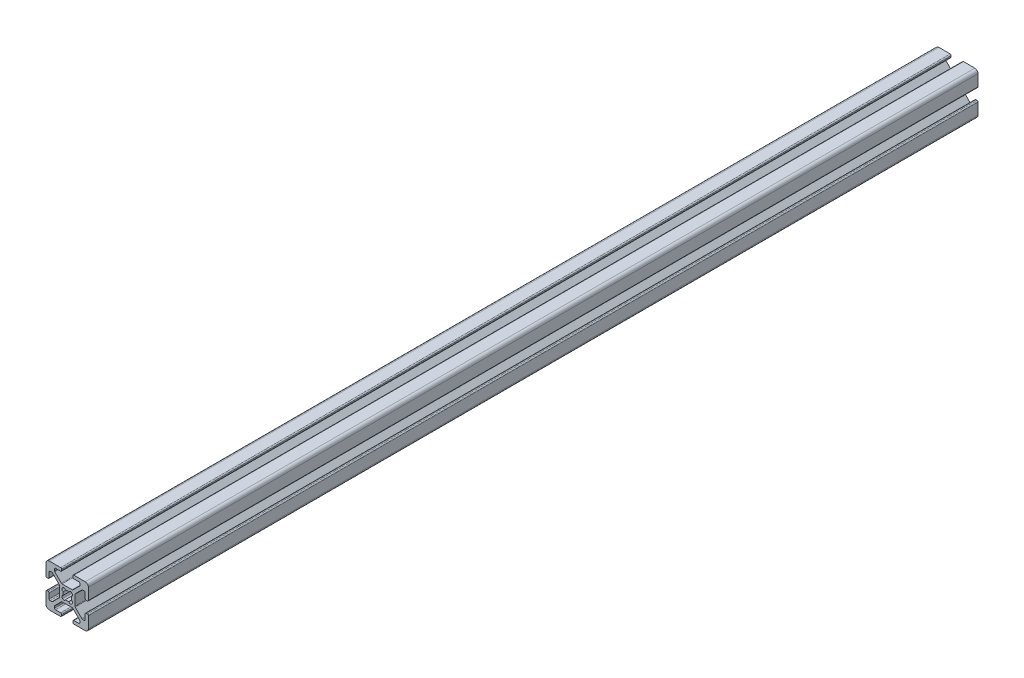
from build123d import *

# Parameters (mm, degrees)
EXTRUDE1_DEPTH = 420


with BuildPart() as part:
    # Sketch1 → Extrude1 (new body)
    with BuildSketch(Plane.XY):
        with BuildLine():
            Line((9.492, 2.63), (9.008, 2.63))
            ThreePointArc((9.008, 2.63), (8.648789755, 2.778789755), (8.5, 3.138))
            Line((8.5, 3.138), (8.5, 5.487))
            ThreePointArc((8.5, 5.487), (8.351210245, 5.846210245), (7.992, 5.995))
            Line((7.992, 5.995), (7.266080661, 5.995))
            ThreePointArc((7.266080661, 5.995), (7.071677478, 5.956330803), (6.906870417, 5.846210245))
            Line((6.906870417, 5.846210245), (3.803789755, 2.743129583))
            ThreePointArc((3.803789755, 2.743129583), (3.693669197, 2.578322522), (3.655, 2.383919339))
            Line((3.655, 2.383919339), (3.655, -2.383919339))
            ThreePointArc((3.655, -2.383919339), (3.693669197, -2.578322522), (3.803789755, -2.743129583))
            Line((3.803789755, -2.743129583), (6.906870417, -5.846210245))
            ThreePointArc((6.906870417, -5.846210245), (7.071677478, -5.956330803), (7.266080661, -5.995))
            Line((7.266080661, -5.995), (7.992, -5.995))
            ThreePointArc((7.992, -5.995), (8.351210245, -5.846210245), (8.5, -5.487))
            Line((8.5, -5.487), (8.5, -3.138))
            ThreePointArc((8.5, -3.138), (8.648789755, -2.778789755), (9.008, -2.63))
            Line((9.008, -2.63), (9.492, -2.63))
            ThreePointArc((9.492, -2.63), (9.851210245, -2.778789755), (10, -3.138))
            Line((10, -3.138), (10, -8.5))
            ThreePointArc((10, -8.5), (9.560660172, -9.560660172), (8.5, -10))
            Line((8.5, -10), (3.138, -10))
            ThreePointArc((3.138, -10), (2.778789755, -9.851210245), (2.63, -9.492))
            Line((2.63, -9.492), (2.63, -9.008))
            ThreePointArc((2.63, -9.008), (2.778789755, -8.648789755), (3.138, -8.5))
            Line((3.138, -8.5), (5.487, -8.5))
            ThreePointArc((5.487, -8.5), (5.846210245, -8.351210245), (5.995, -7.992))
            Line((5.995, -7.992), (5.995, -7.266080661))
            ThreePointArc((5.995, -7.266080661), (5.956330803, -7.071677478), (5.846210245, -6.906870417))
            Line((5.846210245, -6.906870417), (2.743129583, -3.803789755))
            ThreePointArc((2.743129583, -3.803789755), (2.578322522, -3.693669197), (2.383919339, -3.655))
            Line((2.383919339, -3.655), (-2.383919339, -3.655))
            ThreePointArc((-2.383919339, -3.655), (-2.578322522, -3.693669197), (-2.743129583, -3.803789755))
            Line((-2.743129583, -3.803789755), (-5.846210245, -6.906870417))
            ThreePointArc((-5.846210245, -6.906870417), (-5.956330803, -7.071677478), (-5.995, -7.266080661))
            Line((-5.995, -7.266080661), (-5.995, -7.992))
            ThreePointArc((-5.995, -7.992), (-5.846210245, -8.351210245), (-5.487, -8.5))
            Line((-5.487, -8.5), (-3.138, -8.5))
            ThreePointArc((-3.138, -8.5), (-2.778789755, -8.648789755), (-2.63, -9.008))
            Line((-2.63, -9.008), (-2.63, -9.492))
            ThreePointArc((-2.63, -9.492), (-2.778789755, -9.851210245), (-3.138, -10))
            Line((-3.138, -10), (-8.5, -10))
            ThreePointArc((-8.5, -10), (-9.560660172, -9.560660172), (-10, -8.5))
            Line((-10, -8.5), (-10, -3.138))
            ThreePointArc((-10, -3.138), (-9.851210245, -2.778789755), (-9.492, -2.63))
            Line((-9.492, -2.63), (-9.008, -2.63))
            ThreePointArc((-9.008, -2.63), (-8.648789755, -2.778789755), (-8.5, -3.138))
            Line((-8.5, -3.138), (-8.5, -5.487))
            ThreePointArc((-8.5, -5.487), (-8.351210245, -5.846210245), (-7.992, -5.995))
            Line((-7.992, -5.995), (-7.266080661, -5.995))
            ThreePointArc((-7.266080661, -5.995), (-7.071677478, -5.956330803), (-6.906870417, -5.846210245))
            Line((-6.906870417, -5.846210245), (-3.803789755, -2.743129583))
            ThreePointArc((-3.803789755, -2.743129583), (-3.693669197, -2.578322522), (-3.655, -2.383919339))
            Line((-3.655, -2.383919339), (-3.655, 2.383919339))
            ThreePointArc((-3.655, 2.383919339), (-3.693669197, 2.578322522), (-3.803789755, 2.743129583))
            Line((-3.803789755, 2.743129583), (-6.906870417, 5.846210245))
            ThreePointArc((-6.906870417, 5.846210245), (-7.071677478, 5.956330803), (-7.266080661, 5.995))
            Line((-7.266080661, 5.995), (-7.992, 5.995))
            ThreePointArc((-7.992, 5.995), (-8.351210245, 5.846210245), (-8.5, 5.487))
            Line((-8.5, 5.487), (-8.5, 3.138))
            ThreePointArc((-8.5, 3.138), (-8.648789755, 2.778789755), (-9.008, 2.63))
            Line((-9.008, 2.63), (-9.492, 2.63))
            ThreePointArc((-9.492, 2.63), (-9.851210245, 2.778789755), (-10, 3.138))
            Line((-10, 3.138), (-10, 8.5))
            ThreePointArc((-10, 8.5), (-9.560660172, 9.560660172), (-8.5, 10))
            Line((-8.5, 10), (-3.138, 10))
            ThreePointArc((-3.138, 10), (-2.778789755, 9.851210245), (-2.63, 9.492))
            Line((-2.63, 9.492), (-2.63, 9.008))
            ThreePointArc((-2.63, 9.008), (-2.778789755, 8.648789755), (-3.138, 8.5))
            Line((-3.138, 8.5), (-5.487, 8.5))
            ThreePointArc((-5.487, 8.5), (-5.846210245, 8.351210245), (-5.995, 7.992))
            Line((-5.995, 7.992), (-5.995, 7.266080661))
            ThreePointArc((-5.995, 7.266080661), (-5.956330803, 7.071677478), (-5.846210245, 6.906870417))
            Line((-5.846210245, 6.906870417), (-2.743129583, 3.803789755))
            ThreePointArc((-2.743129583, 3.803789755), (-2.578322522, 3.693669197), (-2.383919339, 3.655))
            Line((-2.383919339, 3.655), (2.383919339, 3.655))
            ThreePointArc((2.383919339, 3.655), (2.578322522, 3.693669197), (2.743129583, 3.803789755))
            Line((2.743129583, 3.803789755), (5.846210245, 6.906870417))
            ThreePointArc((5.846210245, 6.906870417), (5.956330803, 7.071677478), (5.995, 7.266080661))
            Line((5.995, 7.266080661), (5.995, 7.992))
            ThreePointArc((5.995, 7.992), (5.846210245, 8.351210245), (5.487, 8.5))
            Line((5.487, 8.5), (3.138, 8.5))
            ThreePointArc((3.138, 8.5), (2.778789755, 8.648789755), (2.63, 9.008))
            Line((2.63, 9.008), (2.63, 9.492))
            ThreePointArc((2.63, 9.492), (2.778789755, 9.851210245), (3.138, 10))
            Line((3.138, 10), (8.5, 10))
            ThreePointArc((8.5, 10), (9.560660172, 9.560660172), (10, 8.5))
            Line((10, 8.5), (10, 3.138))
            ThreePointArc((10, 3.138), (9.851210245, 2.778789755), (9.492, 2.63))
        make_face()
        with BuildLine():
            Line((2.124900844, -2.304505966), (2.304505966, -2.124900844))
            ThreePointArc((2.304505966, -2.124900844), (2.505938017, -1.356467811), (1.935133506, -0.803976718))
            ThreePointArc((1.935133506, -0.803976718), (2.0955, 0), (1.935133506, 0.803976718))
            ThreePointArc((1.935133506, 0.803976718), (2.505938017, 1.356467811), (2.304505966, 2.124900844))
            Line((2.304505966, 2.124900844), (2.124900844, 2.304505966))
            ThreePointArc((2.124900844, 2.304505966), (1.356467811, 2.505938017), (0.803976718, 1.935133506))
            ThreePointArc((0.803976718, 1.935133506), (0, 2.0955), (-0.803976718, 1.935133506))
            ThreePointArc((-0.803976718, 1.935133506), (-1.356467811, 2.505938017), (-2.124900844, 2.304505966))
            Line((-2.124900844, 2.304505966), (-2.304505966, 2.124900844))
            ThreePointArc((-2.304505966, 2.124900844), (-2.505938017, 1.356467811), (-1.935133506, 0.803976718))
            ThreePointArc((-1.935133506, 0.803976718), (-2.0955, 0), (-1.935133506, -0.803976718))
            ThreePointArc((-1.935133506, -0.803976718), (-2.505938017, -1.356467811), (-2.304505966, -2.124900844))
            Line((-2.304505966, -2.124900844), (-2.124900844, -2.304505966))
            ThreePointArc((-2.124900844, -2.304505966), (-1.356467811, -2.505938017), (-0.803976718, -1.935133506))
            ThreePointArc((-0.803976718, -1.935133506), (0, -2.0955), (0.803976718, -1.935133506))
            ThreePointArc((0.803976718, -1.935133506), (1.356467811, -2.505938017), (2.124900844, -2.304505966))
        make_face(mode=Mode.SUBTRACT)
    extrude(amount=-EXTRUDE1_DEPTH)


solid = part.part
